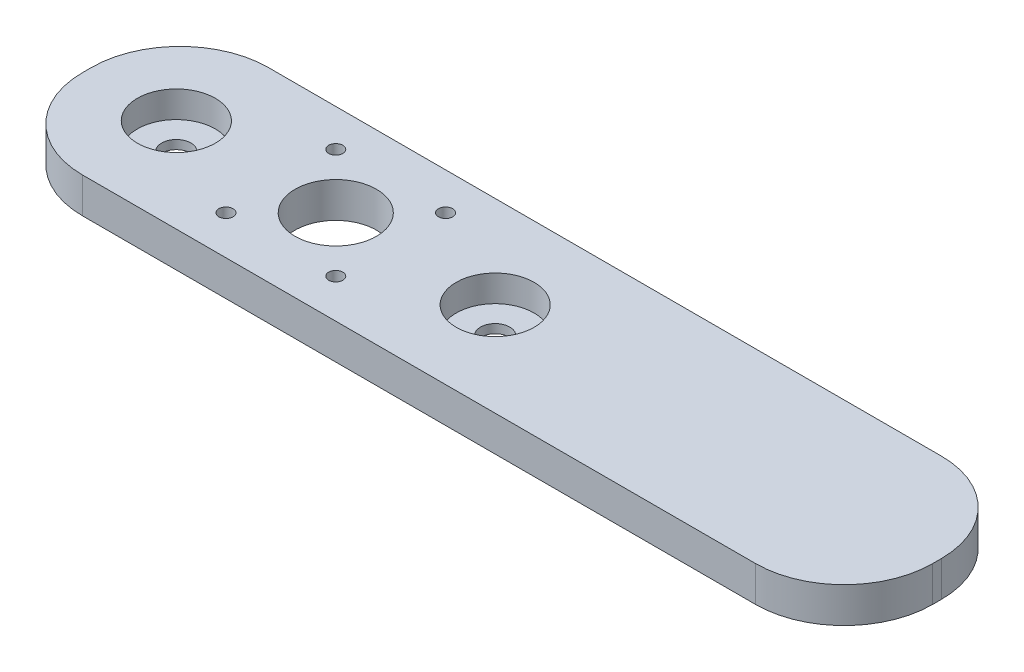
from build123d import *

# Parameters (mm, degrees)
SKETCH1_R           = 11
BOSS_EXTRUDE1_DEPTH = 10
SKETCH2_R           = 11
SKETCH2_R_2         = 4.125
BOSS_EXTRUDE2_DEPTH = 2.5
SKETCH4_R           = 2
SKETCH4_R_2         = 11.5
CUT_EXTRUDE1_DEPTH  = 10
BOSS_EXTRUDE3_DEPTH = 10
BOSS_EXTRUDE4_DEPTH = 10
FILLET1_R           = 25
CUT_EXTRUDE5_DEPTH  = 10
BOSS_EXTRUDE6_DEPTH = 10
FILLET3_R           = 25
BOSS_EXTRUDE7_DEPTH = 10
FILLET4_R           = 25


with BuildPart() as part:
    # Sketch1 → Boss-Extrude1 (new body)
    with BuildSketch(Plane(origin=(0, 0, 0), x_dir=(1, 0, 0), z_dir=(0, 1, 0))):
        with BuildLine():
            Line((-45, -27), (-25, -27))
            Line((-25, -27), (25, -27))
            Line((25, -27), (45, -27))
            Line((45, -27), (70, -27))
            Line((70, -27), (70, -2))
            Line((70, -2), (70, 0))
            ThreePointArc((70, 0), (62.67766953, 17.67766953), (45, 25))
            Line((45, 25), (-45, 25))
            ThreePointArc((-45, 25), (-62.67766953, 17.67766953), (-70, 0))
            Line((-70, 0), (-70, -2))
            Line((-70, -2), (-70, -27))
            Line((-70, -27), (-45, -27))
        make_face()
        with Locations(Location((-45, 0, 0), (0, 0, 90))):  # turned: the seam where the file's is
            Circle(SKETCH1_R, mode=Mode.SUBTRACT)
        with Locations(Location((45, 0, 0), (0, 0, 270))):  # turned: the seam where the file's is
            Circle(SKETCH1_R, mode=Mode.SUBTRACT)
    extrude(amount=BOSS_EXTRUDE1_DEPTH)

    # Sketch2 → Boss-Extrude2 (add)
    with BuildSketch(Plane.XZ):
        with Locations(Location((45, 0, 0), (0, 0, 270))):  # turned: the seam where the file's is
            Circle(SKETCH2_R)
        with Locations(Location((45, 0, 0), (0, 0, 270))):  # turned: the seam where the file's is
            Circle(SKETCH2_R_2, mode=Mode.SUBTRACT)
        with Locations(Location((-45, 0, 0), (0, 0, 270))):  # turned: the seam where the file's is
            Circle(SKETCH2_R)
        with Locations(Location((-45, 0, 0), (0, 0, 270))):  # turned: the seam where the file's is
            Circle(SKETCH2_R_2, mode=Mode.SUBTRACT)
    extrude(amount=-BOSS_EXTRUDE2_DEPTH)

    # Sketch4 → Cut-Extrude1 (cut)
    with BuildSketch(Plane(origin=(0, 10, 0), x_dir=(1, 0, 0), z_dir=(0, 1, 0))):
        with Locations(Location((15.5, 15.5, 0), (0, 0, 270))):  # turned: the seam where the file's is
            Circle(SKETCH4_R)
        with Locations(Location((-15.5, 15.5, 0), (0, 0, 270))):  # turned: the seam where the file's is
            Circle(SKETCH4_R)
        with Locations(Location((-15.5, -15.5, 0), (0, 0, 270))):  # turned: the seam where the file's is
            Circle(SKETCH4_R)
        with Locations(Location((15.5, -15.5, 0), (0, 0, 270))):  # turned: the seam where the file's is
            Circle(SKETCH4_R)
        with Locations(Location((0, 0, 0), (0, 0, 270))):  # turned: the seam where the file's is
            Circle(SKETCH4_R_2)
    extrude(amount=-CUT_EXTRUDE1_DEPTH, mode=Mode.SUBTRACT)

    # Sketch5 → Boss-Extrude3 (add)
    with BuildSketch(Plane(origin=(0, 0, 0), x_dir=(-1, 0, 0), z_dir=(0, -1, 0))):
        Polygon((-70, -27), (-151.373495533, -27), (-151.373495533, 25), (-45, 25), (-50.986838326, 16.31487445), (-65.445821875, 2.682118533), (-66.139224666, -20.893576385), align=None)
    extrude(amount=-BOSS_EXTRUDE3_DEPTH)

    # Sketch6 → Boss-Extrude4 (add)
    with BuildSketch(Plane(origin=(0, 0, 0), x_dir=(-1, 0, 0), z_dir=(0, -1, 0))):
        Polygon((-151.373495533, 25), (-170, 25), (-170, -27), (-151.373495533, -27), (-141.038307318, -1), align=None)
    extrude(amount=-BOSS_EXTRUDE4_DEPTH)

    # Fillet1
    fillet1_edges = [part.edges().sort_by_distance(p)[0] for p in [
        (170, 5, 27),
        (170, 5, -25),
        (-70, 5, 27),
    ]]
    fillet(fillet1_edges, radius=FILLET1_R)

    # Sketch7 → Cut-Extrude5 (cut)
    with BuildSketch(Plane(origin=(0, 10, 0), x_dir=(1, 0, 0), z_dir=(0, 1, 0))):
        with BuildLine():
            Line((133.980635502, -69.297657421), (165.367779164, -26))
            Line((165.367779164, -26), (152, -26))
            ThreePointArc((152, -26), (148.535533906, -26.748737342), (145, -27))
            Line((145, -27), (-45, -27))
            ThreePointArc((-45, -27), (-48.535533906, -26.748737342), (-52, -26))
            Line((-52, -26), (-59.265699986, -26))
            Line((-59.265699986, -26), (-45.110713629, -66.528203569))
            Line((-45.110713629, -66.528203569), (133.980635502, -69.297657421))
        make_face()
        with BuildLine():
            ThreePointArc((145, -27), (148.535533906, -26.748737342), (152, -26))
            Line((152, -26), (-52, -26))
            ThreePointArc((-52, -26), (-48.535533906, -26.748737342), (-45, -27))
            Line((-45, -27), (145, -27))
        make_face()
    extrude(amount=-CUT_EXTRUDE5_DEPTH, mode=Mode.SUBTRACT)

    # Sketch10 → Boss-Extrude6 (add)
    with BuildSketch(Plane(origin=(0, 10, 0), x_dir=(1, 0, 0), z_dir=(0, 1, 0))):
        with BuildLine():
            Line((-63.907316272, 7.976406282), (-70, 0))
            ThreePointArc((-70, 0), (-62.67766953, 17.67766953), (-45, 25))
            Line((-45, 25), (145, 25))
            ThreePointArc((145, 25), (162.67766953, 17.67766953), (170, 0))
            Line((170, 0), (55.598298081, 15.952812565))
            Line((55.598298081, 15.952812565), (0, 23.705749919))
            Line((0, 23.705749919), (-30.230523, 19.829281242))
            Line((-30.230523, 19.829281242), (-63.907316272, 7.976406282))
        make_face()
        with BuildLine():
            Line((-70, 0), (-70, 26))
            Line((-70, 26), (170, 26))
            Line((170, 26), (170, 0))
            ThreePointArc((170, 0), (162.67766953, 17.67766953), (145, 25))
            Line((145, 25), (-45, 25))
            ThreePointArc((-45, 25), (-62.67766953, 17.67766953), (-70, 0))
        make_face()
    extrude(amount=-BOSS_EXTRUDE6_DEPTH)

    # Fillet3
    fillet3_edges = [part.edges().sort_by_distance(p)[0] for p in [
        (-70, 5, -26),
        (170, 5, -26),
    ]]
    fillet(fillet3_edges, radius=FILLET3_R)

    # Sketch11 → Boss-Extrude7 (add)
    with BuildSketch(Plane(origin=(0, 10, 0), x_dir=(1, 0, 0), z_dir=(0, 1, 0))):
        with BuildLine():
            Line((170, -2), (170, -0.5))
            Line((170, -0.5), (142.437846572, -19.831941741))
            Line((142.437846572, -19.831941741), (-54.330276999, -19.831941741))
            Line((-54.330276999, -19.831941741), (-70, -0.5))
            Line((-70, -0.5), (-70, -2))
            ThreePointArc((-70, -2), (-65, -17), (-52, -26))
            Line((-52, -26), (152, -26))
            ThreePointArc((152, -26), (165, -17), (170, -2))
        make_face()
        with BuildLine():
            Line((170, -26.5), (170, -2))
            ThreePointArc((170, -2), (165, -17), (152, -26))
            Line((152, -26), (-52, -26))
            ThreePointArc((-52, -26), (-65, -17), (-70, -2))
            Line((-70, -2), (-70, -26.5))
            Line((-70, -26.5), (170, -26.5))
        make_face()
    extrude(amount=-BOSS_EXTRUDE7_DEPTH)

    # Fillet4
    fillet4_edges = [part.edges().sort_by_distance(p)[0] for p in [
        (-70, 5, 26.5),
        (170, 5, 26.5),
    ]]
    fillet(fillet4_edges, radius=FILLET4_R)


solid = part.part
